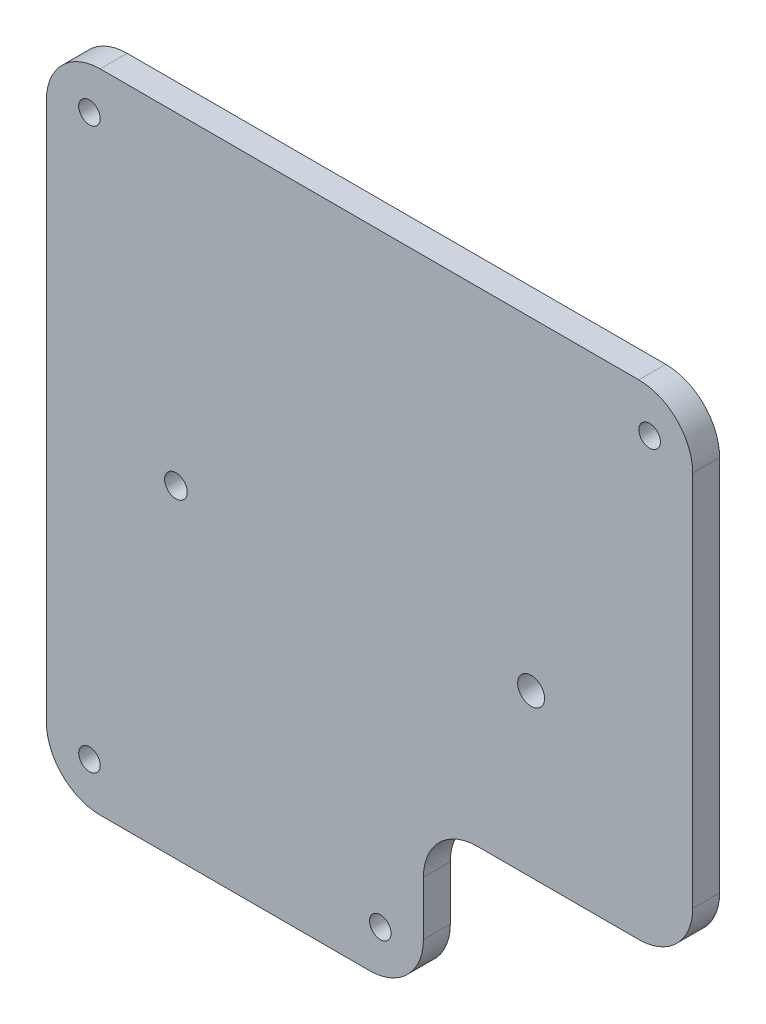
from build123d import *

# Parameters (mm, degrees)
SALIENTE_EXTRUIR1_DEPTH = 5
CROQUIS2_R              = 2
CROQUIS2_R_2            = 2.5
CROQUIS2_R_3            = 2.1
CORTAR_EXTRUIR1_DEPTH   = 10


with BuildPart() as part:
    # Croquis1 → Saliente-Extruir1 (new body)
    with BuildSketch(Plane.XY):
        with BuildLine():
            Line((110, 30), (80, 30))
            ThreePointArc((80, 30), (72.928932188, 27.071067812), (70, 20))
            Line((70, 20), (70, 10))
            ThreePointArc((70, 10), (67.071067812, 2.928932188), (60, 0))
            Line((60, 0), (10, 0))
            ThreePointArc((10, 0), (2.928932188, 2.928932188), (0, 10))
            Line((0, 10), (0, 110))
            ThreePointArc((0, 110), (2.928932188, 117.071067812), (10, 120))
            Line((10, 120), (110, 120))
            ThreePointArc((110, 120), (117.071067812, 117.071067812), (120, 110))
            Line((120, 110), (120, 40))
            ThreePointArc((120, 40), (117.071067812, 32.928932188), (110, 30))
        make_face()
    extrude(amount=SALIENTE_EXTRUIR1_DEPTH)

    # Croquis2 → Cortar-Extruir1 (cut)
    with BuildSketch(Plane.XY.offset(5)):
        with Locations((8, 112)):
            Circle(CROQUIS2_R)
        with Locations((8, 8)):
            Circle(CROQUIS2_R)
        with Locations((112, 8)):
            Circle(CROQUIS2_R)
        with Locations((112, 112)):
            Circle(CROQUIS2_R)
        with Locations((90, 60)):
            Circle(CROQUIS2_R_2)
        with Locations((62, 8)):
            Circle(CROQUIS2_R)
        with Locations((24.06, 60)):
            Circle(CROQUIS2_R_3)
    extrude(amount=-CORTAR_EXTRUIR1_DEPTH, mode=Mode.SUBTRACT)


solid = part.part
